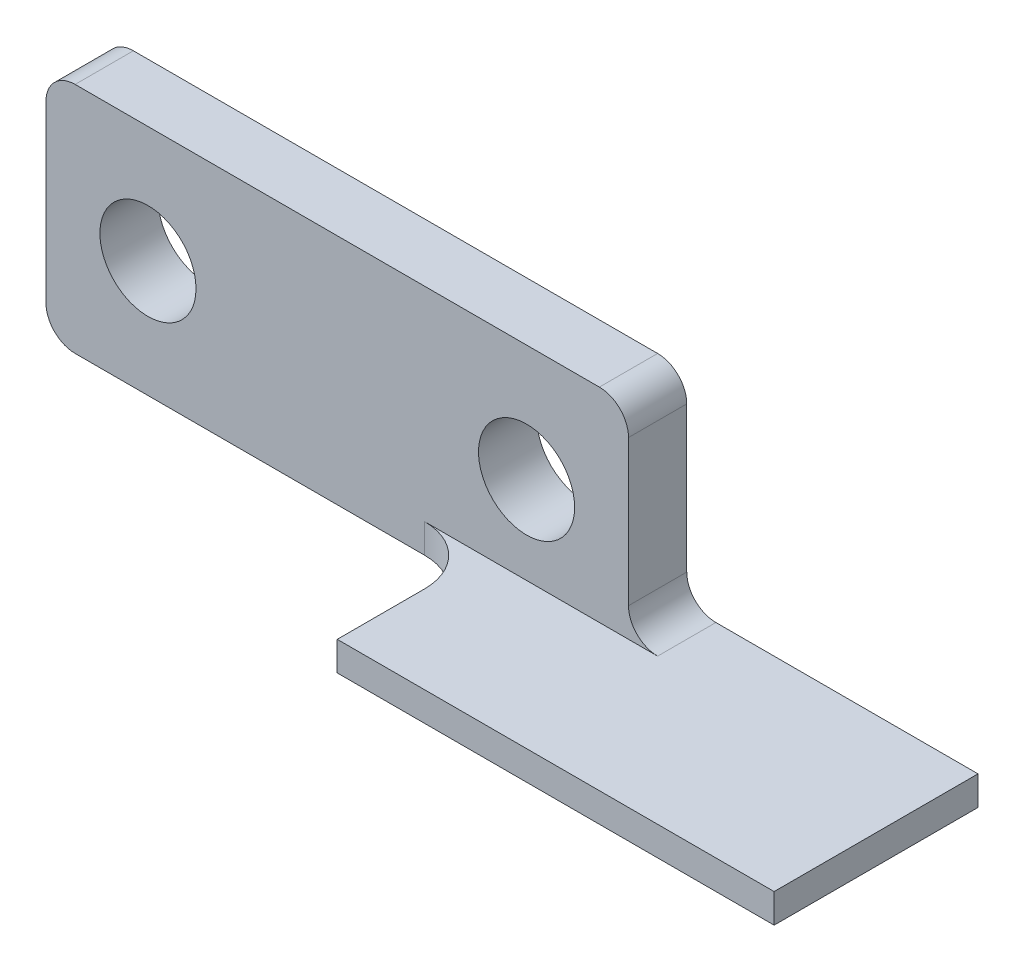
from build123d import *

# Parameters (mm, degrees)
SKETCH1_W                = 20
SKETCH1_H                = 8
BOSS_EXTRUDE1_DEPTH      = 2
SKETCH2_W                = 15
SKETCH2_H                = 1
BOSS_EXTRUDE2_DEPTH      = 5
BOSS_EXTRUDE2_DEPTH_BACK = 2
SKETCH3_R                = 1.65
CUT_EXTRUDE1_DEPTH       = 3
FILLET1_R                = 1
FILLET2_R                = 2


with BuildPart() as part:
    # Sketch1 → Boss-Extrude1 (new body)
    with BuildSketch(Plane.XY):
        with Locations((10, 4)):
            Rectangle(SKETCH1_W, SKETCH1_H)
    extrude(amount=BOSS_EXTRUDE1_DEPTH)

    # Sketch2 → Boss-Extrude2 (add, two sides)
    with BuildSketch(Plane.XY.offset(2)) as boss_extrude2_sk:
        with Locations((22.5, 0.5)):
            Rectangle(SKETCH2_W, SKETCH2_H)
    extrude(amount=BOSS_EXTRUDE2_DEPTH)
    extrude(boss_extrude2_sk.sketch, amount=-BOSS_EXTRUDE2_DEPTH_BACK)

    # Sketch3 → Cut-Extrude1 (cut, through all)
    with BuildSketch(Plane.XY.offset(2)):
        with Locations((3.5, 4)):
            Circle(SKETCH3_R)
        with Locations((16.5, 4)):
            Circle(SKETCH3_R)
    extrude(amount=-CUT_EXTRUDE1_DEPTH, mode=Mode.SUBTRACT)

    # Fillet1
    fillet1_edges = [part.edges().sort_by_distance(p)[0] for p in [
        (20, 1, 1),
        (0, 8, 1),
        (20, 8, 1),
        (0, 0, 1),
    ]]
    fillet(fillet1_edges, radius=FILLET1_R)

    # Fillet2
    fillet2_edges = [part.edges().sort_by_distance(p)[0] for p in [
        (15, 0.5, 2),
    ]]
    fillet(fillet2_edges, radius=FILLET2_R)


solid = part.part
